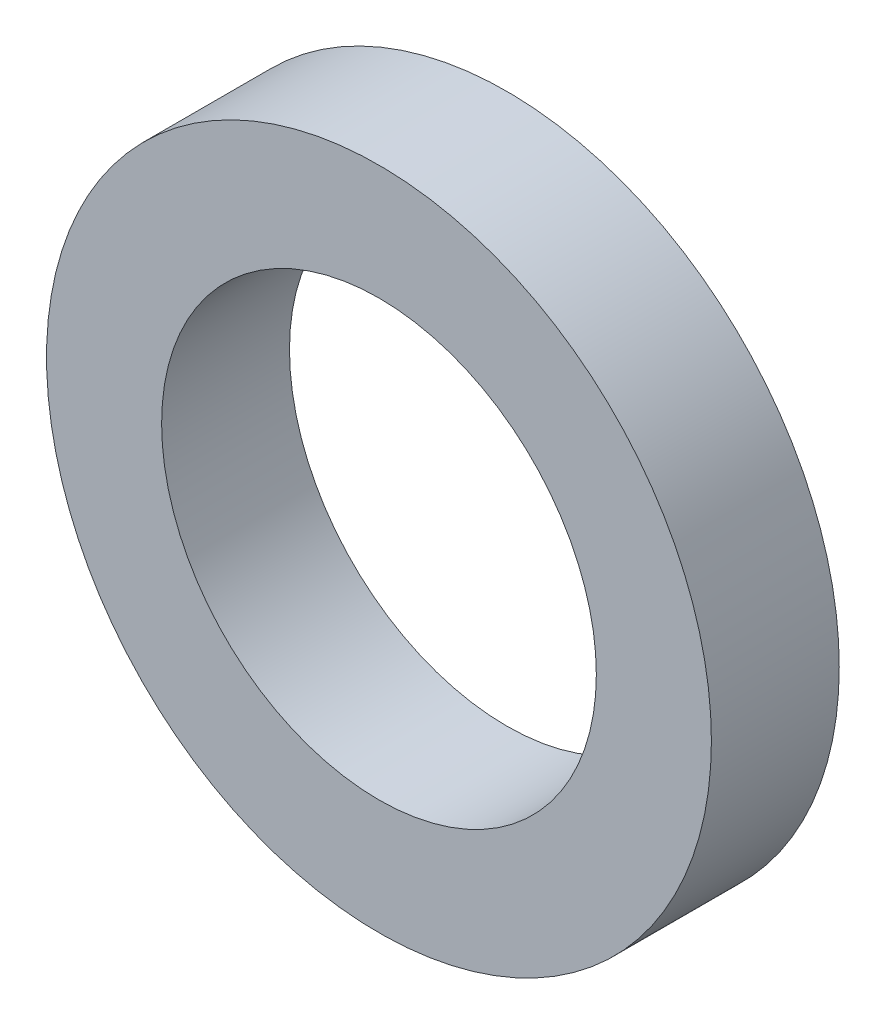
from build123d import *

# Parameters (mm, degrees)
SKETCH_1_R      = 13
SKETCH_1_R_2    = 8.5
EXTRUDE_1_DEPTH = 5


with BuildPart() as part:
    # Эскиз1 → Бобышка-Вытянуть1 (new body)
    with BuildSketch(Plane.XY):
        Circle(SKETCH_1_R)
        Circle(SKETCH_1_R_2, mode=Mode.SUBTRACT)
    extrude(amount=EXTRUDE_1_DEPTH)


solid = part.part
